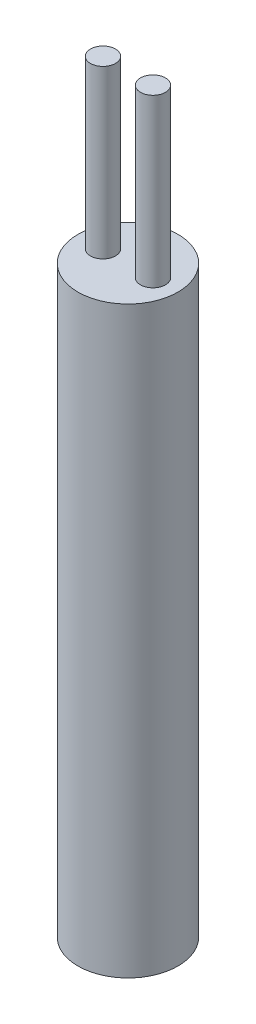
from build123d import *

# Parameters (mm, degrees)
SKETCH1_R           = 3
BOSS_EXTRUDE1_DEPTH = 35
SKETCH2_R           = 0.75
BOSS_EXTRUDE2_DEPTH = 10


with BuildPart() as part:
    # Sketch1 → Boss-Extrude1 (new body)
    with BuildSketch(Plane(origin=(0, 0, 0), x_dir=(1, 0, 0), z_dir=(0, 1, 0))):
        Circle(SKETCH1_R)
    extrude(amount=BOSS_EXTRUDE1_DEPTH)

    # Sketch2 → Boss-Extrude2 (add)
    with BuildSketch(Plane(origin=(0, 35, 0), x_dir=(1, 0, 0), z_dir=(0, 1, 0))):
        with Locations((1.5, 0)):
            Circle(SKETCH2_R)
        with Locations((-1.5, 0)):
            Circle(SKETCH2_R)
    extrude(amount=BOSS_EXTRUDE2_DEPTH)


solid = part.part
